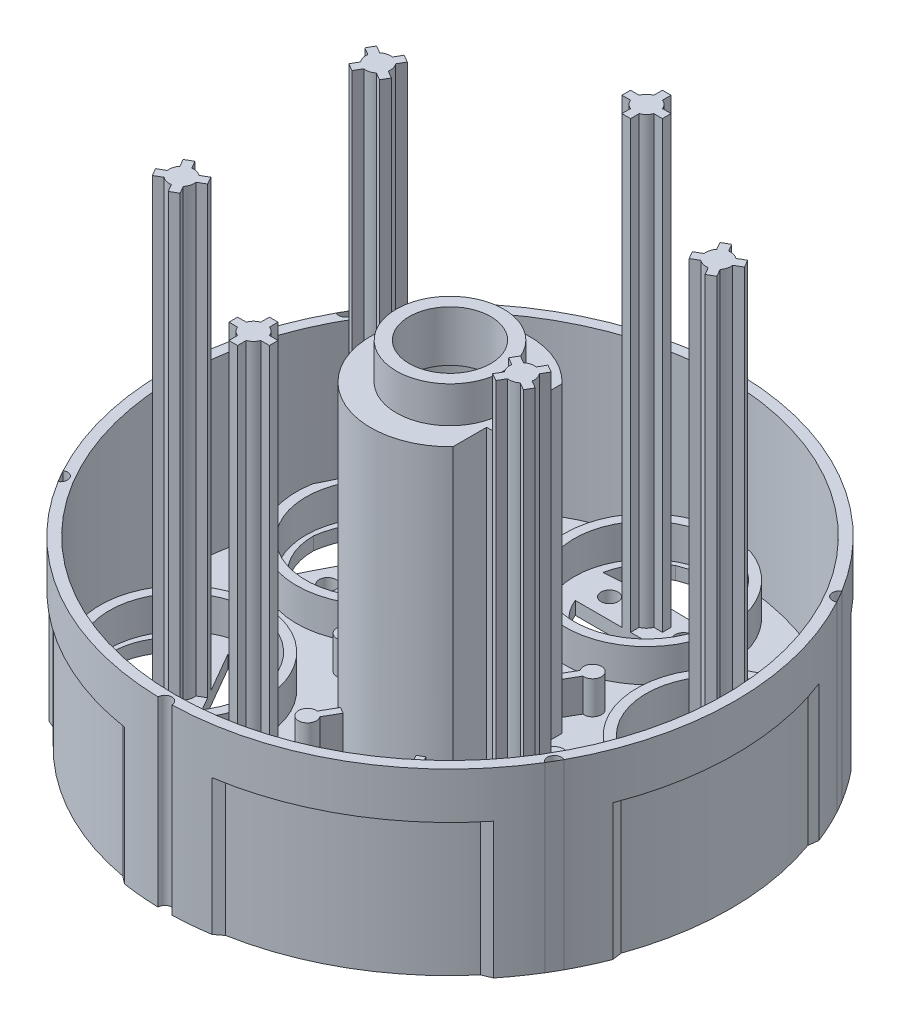
from build123d import *

# Parameters (mm, degrees)
SKETCH1_R           = 30.63
BOSS_EXTRUDE1_DEPTH = 19.56
SKETCH2_R           = 29.5
CUT_EXTRUDE1_DEPTH  = 18.17
SKETCH4_R           = 8.515
BOSS_EXTRUDE2_DEPTH = 36.43
SKETCH5_R           = 8.515
SKETCH5_R_2         = 5.765
CUT_EXTRUDE2_DEPTH  = 3.9
SKETCH6_R           = 4.38
CUT_EXTRUDE3_DEPTH  = 58.504314621
CUT_EXTRUDE4_DEPTH  = 32.53
CUT_EXTRUDE5_DEPTH  = 32.37
BOSS_EXTRUDE3_DEPTH = 3.54
SKETCH10_R          = 8.75
SKETCH10_R_2        = 7.75
BOSS_EXTRUDE7_DEPTH = 3.54
BOSS_EXTRUDE9_DEPTH = 47.8
SKETCH13_R          = 0.909625742
CUT_EXTRUDE8_DEPTH  = 65.507625906
CUT_EXTRUDE10_DEPTH = 14.59
CUT_EXTRUDE11_DEPTH = 66.544259093


with BuildPart() as part:
    # Sketch1 → Boss-Extrude1 (new body)
    with BuildSketch(Plane(origin=(0, 0, 0), x_dir=(1, 0, 0), z_dir=(0, 1, 0))):
        with Locations(Location((0, 0, 0), (0, 0, 270))):
            Circle(SKETCH1_R)
    extrude(amount=BOSS_EXTRUDE1_DEPTH)

    # Sketch2 → Cut-Extrude1 (cut)
    with BuildSketch(Plane(origin=(0, 19.56, 0), x_dir=(1, 0, 0), z_dir=(0, 1, 0))):
        with Locations(Location((0, 0, 0), (0, 0, 270))):
            Circle(SKETCH2_R)
    extrude(amount=-CUT_EXTRUDE1_DEPTH, mode=Mode.SUBTRACT)

    # Sketch4 → Boss-Extrude2 (add)
    with BuildSketch(Plane(origin=(0, 1.39, 0), x_dir=(1, 0, 0), z_dir=(0, 1, 0))):
        with Locations(Location((0, 0, 0), (0, 0, 90))):
            Circle(SKETCH4_R)
    extrude(amount=BOSS_EXTRUDE2_DEPTH)

    # Sketch5 → Cut-Extrude2 (cut)
    with BuildSketch(Plane(origin=(0, 37.82, 0), x_dir=(1, 0, 0), z_dir=(0, 1, 0))):
        with Locations(Location((0, 0, 0), (0, 0, 90))):
            Circle(SKETCH5_R)
        with Locations(Location((0, 0, 0), (0, 0, 270))):
            Circle(SKETCH5_R_2, mode=Mode.SUBTRACT)
    extrude(amount=-CUT_EXTRUDE2_DEPTH, mode=Mode.SUBTRACT)

    # Sketch6 → Cut-Extrude3 (cut, through all)
    with BuildSketch(Plane(origin=(0, 37.82, 0), x_dir=(1, 0, 0), z_dir=(0, 1, 0))):
        with Locations(Location((0, 0, 0), (0, 0, 270))):
            Circle(SKETCH6_R)
    extrude(amount=-CUT_EXTRUDE3_DEPTH, mode=Mode.SUBTRACT)

    # Sketch7 → Cut-Extrude4 (cut)
    with BuildSketch(Plane(origin=(0, 33.92, 0), x_dir=(1, 0, 0), z_dir=(0, 1, 0))):
        with BuildLine():
            Line((8.213720229, 2.245), (6.181644869, 2.245))
            Line((6.181644869, 2.245), (6.181644869, 5.855979142))
            ThreePointArc((6.181644869, 5.855979142), (7.420675621, 4.175978728), (8.213720229, 2.245))
        make_face()
        with BuildLine():
            Line((8.213720229, -2.245), (6.181644869, -2.245))
            Line((6.181644869, -2.245), (6.181644869, -5.855979142))
            ThreePointArc((6.181644869, -5.855979142), (7.420675621, -4.175978728), (8.213720229, -2.245))
        make_face()
    extrude(amount=-CUT_EXTRUDE4_DEPTH, mode=Mode.SUBTRACT)

    # Sketch8 → Cut-Extrude5 (cut)
    with BuildSketch(Plane.XZ):
        with BuildLine():
            Line((7.200999931, -1.035), (6.115, -1.035))
            Line((6.115, -1.035), (6.115, -3.941116593))
            ThreePointArc((6.115, -3.941116593), (-7.275, 0), (6.115, 3.941116593))
            Line((6.115, 3.941116593), (6.115, 1.035))
            Line((6.115, 1.035), (7.200999931, 1.035))
            ThreePointArc((7.200999931, 1.035), (7.275, 0), (7.200999931, -1.035))
        make_face()
    extrude(amount=-CUT_EXTRUDE5_DEPTH, mode=Mode.SUBTRACT)

    # Sketch9 → Boss-Extrude3 (add)
    with BuildSketch(Plane(origin=(0, 1.39, 0), x_dir=(1, 0, 0), z_dir=(0, 1, 0))):
        with BuildLine():
            Line((8.506232996, 0.386296797), (10.339031796, 0.386296797))
            ThreePointArc((10.339031796, 0.386296797), (12.171005542, 0), (10.339031796, -0.386296797))
            Line((10.339031796, -0.386296797), (8.506232996, -0.386296797))
            ThreePointArc((8.506232996, -0.386296797), (8.515, 0), (8.506232996, 0.386296797))
        make_face()
        with BuildLine():
            Line((4.587659337, -7.173465467), (5.504058737, -8.760715787))
            ThreePointArc((5.504058737, -8.760715787), (6.085502771, -10.540399989), (4.834973059, -9.147012584))
            Line((4.834973059, -9.147012584), (3.918573659, -7.559762263))
            ThreePointArc((3.918573659, -7.559762263), (4.2575, -7.374206313), (4.587659337, -7.173465467))
        make_face()
        with BuildLine():
            Line((-3.918573659, -7.559762263), (-4.834973059, -9.147012584))
            ThreePointArc((-4.834973059, -9.147012584), (-6.085502771, -10.540399989), (-5.504058737, -8.760715787))
            Line((-5.504058737, -8.760715787), (-4.587659337, -7.173465467))
            ThreePointArc((-4.587659337, -7.173465467), (-4.2575, -7.374206313), (-3.918573659, -7.559762263))
        make_face()
        with BuildLine():
            Line((-8.506232996, -0.386296797), (-10.339031796, -0.386296797))
            ThreePointArc((-10.339031796, -0.386296797), (-12.171005542, 0), (-10.339031796, 0.386296797))
            Line((-10.339031796, 0.386296797), (-8.506232996, 0.386296797))
            ThreePointArc((-8.506232996, 0.386296797), (-8.515, 0), (-8.506232996, -0.386296797))
        make_face()
        with BuildLine():
            Line((-4.587659337, 7.173465467), (-5.504058737, 8.760715787))
            ThreePointArc((-5.504058737, 8.760715787), (-6.085502771, 10.540399989), (-4.834973059, 9.147012584))
            Line((-4.834973059, 9.147012584), (-3.918573659, 7.559762263))
            ThreePointArc((-3.918573659, 7.559762263), (-4.2575, 7.374206313), (-4.587659337, 7.173465467))
        make_face()
        with BuildLine():
            Line((3.918573659, 7.559762263), (4.834973059, 9.147012584))
            ThreePointArc((4.834973059, 9.147012584), (6.085502771, 10.540399989), (5.504058737, 8.760715787))
            Line((5.504058737, 8.760715787), (4.587659337, 7.173465467))
            ThreePointArc((4.587659337, 7.173465467), (4.2575, 7.374206313), (3.918573659, 7.559762263))
        make_face()
    extrude(amount=BOSS_EXTRUDE3_DEPTH)

    # Sketch10 → Boss-Extrude7 (add)
    with BuildSketch(Plane(origin=(0, 1.39, 0), x_dir=(1, 0, 0), z_dir=(0, 1, 0))):
        with Locations((0, 21.110003347)):
            Circle(SKETCH10_R)
        with Locations(Location((0, 21.110003347, 0), (0, 0, 90))):
            Circle(SKETCH10_R_2, mode=Mode.SUBTRACT)
        with Locations((18.281799173, 10.555001674)):
            Circle(SKETCH10_R)
        with Locations(Location((18.281799173, 10.555001674, 0), (0, 0, 90))):
            Circle(SKETCH10_R_2, mode=Mode.SUBTRACT)
        with Locations((18.281799173, -10.555001674)):
            Circle(SKETCH10_R)
        with Locations(Location((18.281799173, -10.555001674, 0), (0, 0, 90))):
            Circle(SKETCH10_R_2, mode=Mode.SUBTRACT)
        with Locations((0, -21.110003347)):
            Circle(SKETCH10_R)
        with Locations(Location((0, -21.110003347, 0), (0, 0, 90))):
            Circle(SKETCH10_R_2, mode=Mode.SUBTRACT)
        with Locations((-18.281799173, -10.555001674)):
            Circle(SKETCH10_R)
        with Locations(Location((-18.281799173, -10.555001674, 0), (0, 0, 90))):
            Circle(SKETCH10_R_2, mode=Mode.SUBTRACT)
        with Locations((-18.281799173, 10.555001674)):
            Circle(SKETCH10_R)
        with Locations(Location((-18.281799173, 10.555001674, 0), (0, 0, 90))):
            Circle(SKETCH10_R_2, mode=Mode.SUBTRACT)
    extrude(amount=BOSS_EXTRUDE7_DEPTH)

    # Sketch11 → Boss-Extrude9 (add)
    with BuildSketch(Plane(origin=(0, 1.39, 0), x_dir=(1, 0, 0), z_dir=(0, 1, 0))):
        with BuildLine():
            Line((-0.465, 19.863939545), (-0.465, 18.935802576))
            Line((-0.465, 18.935802576), (0.465, 18.935802576))
            Line((0.465, 18.935802576), (0.465, 19.863939545))
            ThreePointArc((0.465, 19.863939545), (0.940452019, 20.169551328), (1.246063803, 20.645003347))
            Line((1.246063803, 20.645003347), (2.174200772, 20.645003347))
            Line((2.174200772, 20.645003347), (2.174200772, 21.575003347))
            Line((2.174200772, 21.575003347), (1.246063803, 21.575003347))
            ThreePointArc((1.246063803, 21.575003347), (0.940452019, 22.050455366), (0.465, 22.35606715))
            Line((0.465, 22.35606715), (0.465, 23.284204119))
            Line((0.465, 23.284204119), (-0.465, 23.284204119))
            Line((-0.465, 23.284204119), (-0.465, 22.35606715))
            ThreePointArc((-0.465, 22.35606715), (-0.940452019, 22.050455366), (-1.246063803, 21.575003347))
            Line((-1.246063803, 21.575003347), (-2.174200772, 21.575003347))
            Line((-2.174200772, 21.575003347), (-2.174200772, 20.645003347))
            Line((-2.174200772, 20.645003347), (-1.246063803, 20.645003347))
            ThreePointArc((-1.246063803, 20.645003347), (-0.940452019, 20.169551328), (-0.465, 19.863939545))
        make_face()
        with BuildLine():
            Line((16.970176265, 10.334671585), (16.166386071, 9.870603101))
            Line((16.166386071, 9.870603101), (16.631386071, 9.065199475))
            Line((16.631386071, 9.065199475), (17.435176265, 9.52926796))
            ThreePointArc((17.435176265, 9.52926796), (17.937569843, 9.270320325), (18.502129261, 9.243378766))
            Line((18.502129261, 9.243378766), (18.966197746, 8.439588572))
            Line((18.966197746, 8.439588572), (19.771601371, 8.904588572))
            Line((19.771601371, 8.904588572), (19.307532887, 9.708378766))
            ThreePointArc((19.307532887, 9.708378766), (19.566480522, 10.210772344), (19.59342208, 10.775331762))
            Line((19.59342208, 10.775331762), (20.397212274, 11.239400247))
            Line((20.397212274, 11.239400247), (19.932212274, 12.044803872))
            Line((19.932212274, 12.044803872), (19.12842208, 11.580735388))
            ThreePointArc((19.12842208, 11.580735388), (18.626028503, 11.839683023), (18.061469084, 11.866624581))
            Line((18.061469084, 11.866624581), (17.5974006, 12.670414775))
            Line((17.5974006, 12.670414775), (16.791996974, 12.205414775))
            Line((16.791996974, 12.205414775), (17.256065459, 11.401624581))
            ThreePointArc((17.256065459, 11.401624581), (16.997117824, 10.899231004), (16.970176265, 10.334671585))
        make_face()
        with BuildLine():
            Line((17.435176265, -9.52926796), (16.631386071, -9.065199475))
            Line((16.631386071, -9.065199475), (16.166386071, -9.870603101))
            Line((16.166386071, -9.870603101), (16.970176265, -10.334671585))
            ThreePointArc((16.970176265, -10.334671585), (16.997117824, -10.899231004), (17.256065459, -11.401624581))
            Line((17.256065459, -11.401624581), (16.791996974, -12.205414775))
            Line((16.791996974, -12.205414775), (17.5974006, -12.670414775))
            Line((17.5974006, -12.670414775), (18.061469084, -11.866624581))
            ThreePointArc((18.061469084, -11.866624581), (18.626028503, -11.839683023), (19.12842208, -11.580735388))
            Line((19.12842208, -11.580735388), (19.932212274, -12.044803872))
            Line((19.932212274, -12.044803872), (20.397212274, -11.239400247))
            Line((20.397212274, -11.239400247), (19.59342208, -10.775331762))
            ThreePointArc((19.59342208, -10.775331762), (19.566480522, -10.210772344), (19.307532887, -9.708378766))
            Line((19.307532887, -9.708378766), (19.771601371, -8.904588572))
            Line((19.771601371, -8.904588572), (18.966197746, -8.439588572))
            Line((18.966197746, -8.439588572), (18.502129261, -9.243378766))
            ThreePointArc((18.502129261, -9.243378766), (17.937569843, -9.270320325), (17.435176265, -9.52926796))
        make_face()
        with BuildLine():
            Line((0.465, -19.863939545), (0.465, -18.935802576))
            Line((0.465, -18.935802576), (-0.465, -18.935802576))
            Line((-0.465, -18.935802576), (-0.465, -19.863939545))
            ThreePointArc((-0.465, -19.863939545), (-0.940452019, -20.169551328), (-1.246063803, -20.645003347))
            Line((-1.246063803, -20.645003347), (-2.174200772, -20.645003347))
            Line((-2.174200772, -20.645003347), (-2.174200772, -21.575003347))
            Line((-2.174200772, -21.575003347), (-1.246063803, -21.575003347))
            ThreePointArc((-1.246063803, -21.575003347), (-0.940452019, -22.050455366), (-0.465, -22.35606715))
            Line((-0.465, -22.35606715), (-0.465, -23.284204119))
            Line((-0.465, -23.284204119), (0.465, -23.284204119))
            Line((0.465, -23.284204119), (0.465, -22.35606715))
            ThreePointArc((0.465, -22.35606715), (0.940452019, -22.050455366), (1.246063803, -21.575003347))
            Line((1.246063803, -21.575003347), (2.174200772, -21.575003347))
            Line((2.174200772, -21.575003347), (2.174200772, -20.645003347))
            Line((2.174200772, -20.645003347), (1.246063803, -20.645003347))
            ThreePointArc((1.246063803, -20.645003347), (0.940452019, -20.169551328), (0.465, -19.863939545))
        make_face()
        with BuildLine():
            Line((-16.970176265, -10.334671585), (-16.166386071, -9.870603101))
            Line((-16.166386071, -9.870603101), (-16.631386071, -9.065199475))
            Line((-16.631386071, -9.065199475), (-17.435176265, -9.52926796))
            ThreePointArc((-17.435176265, -9.52926796), (-17.937569843, -9.270320325), (-18.502129261, -9.243378766))
            Line((-18.502129261, -9.243378766), (-18.966197746, -8.439588572))
            Line((-18.966197746, -8.439588572), (-19.771601371, -8.904588572))
            Line((-19.771601371, -8.904588572), (-19.307532887, -9.708378766))
            ThreePointArc((-19.307532887, -9.708378766), (-19.566480522, -10.210772344), (-19.59342208, -10.775331762))
            Line((-19.59342208, -10.775331762), (-20.397212274, -11.239400247))
            Line((-20.397212274, -11.239400247), (-19.932212274, -12.044803872))
            Line((-19.932212274, -12.044803872), (-19.12842208, -11.580735388))
            ThreePointArc((-19.12842208, -11.580735388), (-18.626028503, -11.839683023), (-18.061469084, -11.866624581))
            Line((-18.061469084, -11.866624581), (-17.5974006, -12.670414775))
            Line((-17.5974006, -12.670414775), (-16.791996974, -12.205414775))
            Line((-16.791996974, -12.205414775), (-17.256065459, -11.401624581))
            ThreePointArc((-17.256065459, -11.401624581), (-16.997117824, -10.899231004), (-16.970176265, -10.334671585))
        make_face()
        with BuildLine():
            Line((-17.435176265, 9.52926796), (-16.631386071, 9.065199475))
            Line((-16.631386071, 9.065199475), (-16.166386071, 9.870603101))
            Line((-16.166386071, 9.870603101), (-16.970176265, 10.334671585))
            ThreePointArc((-16.970176265, 10.334671585), (-16.997117824, 10.899231004), (-17.256065459, 11.401624581))
            Line((-17.256065459, 11.401624581), (-16.791996974, 12.205414775))
            Line((-16.791996974, 12.205414775), (-17.5974006, 12.670414775))
            Line((-17.5974006, 12.670414775), (-18.061469084, 11.866624581))
            ThreePointArc((-18.061469084, 11.866624581), (-18.626028503, 11.839683023), (-19.12842208, 11.580735388))
            Line((-19.12842208, 11.580735388), (-19.932212274, 12.044803872))
            Line((-19.932212274, 12.044803872), (-20.397212274, 11.239400247))
            Line((-20.397212274, 11.239400247), (-19.59342208, 10.775331762))
            ThreePointArc((-19.59342208, 10.775331762), (-19.566480522, 10.210772344), (-19.307532887, 9.708378766))
            Line((-19.307532887, 9.708378766), (-19.771601371, 8.904588572))
            Line((-19.771601371, 8.904588572), (-18.966197746, 8.439588572))
            Line((-18.966197746, 8.439588572), (-18.502129261, 9.243378766))
            ThreePointArc((-18.502129261, 9.243378766), (-17.937569843, 9.270320325), (-17.435176265, 9.52926796))
        make_face()
    extrude(amount=BOSS_EXTRUDE9_DEPTH)

    # Sketch13 → Cut-Extrude8 (cut, through all)
    with BuildSketch(Plane(origin=(0, 1.39, 0), x_dir=(1, 0, 0), z_dir=(0, 1, 0))):
        with Locations(Location((-3.969867119, 21.110003347, 0), (0, 0, 270))):
            Circle(SKETCH13_R)
        with Locations(Location((3.969867119, 21.110003347, 0), (0, 0, 90))):
            Circle(SKETCH13_R)
        with Locations(Location((16.296865613, 13.993007448, 0), (0, 0, 270))):
            Circle(SKETCH13_R)
        with Locations(Location((20.266732732, 7.116995899, 0), (0, 0, 90))):
            Circle(SKETCH13_R)
        with Locations(Location((20.266732732, -7.116995899, 0), (0, 0, 270))):
            Circle(SKETCH13_R)
        with Locations(Location((16.296865613, -13.993007448, 0), (0, 0, 90))):
            Circle(SKETCH13_R)
        with Locations(Location((3.969867119, -21.110003347, 0), (0, 0, 270))):
            Circle(SKETCH13_R)
        with Locations(Location((-3.969867119, -21.110003347, 0), (0, 0, 90))):
            Circle(SKETCH13_R)
        with Locations(Location((-16.296865613, -13.993007448, 0), (0, 0, 270))):
            Circle(SKETCH13_R)
        with Locations(Location((-20.266732732, -7.116995899, 0), (0, 0, 90))):
            Circle(SKETCH13_R)
        with Locations(Location((-20.266732732, 7.116995899, 0), (0, 0, 270))):
            Circle(SKETCH13_R)
        with Locations(Location((-16.296865613, 13.993007448, 0), (0, 0, 90))):
            Circle(SKETCH13_R)
        with BuildLine():
            Line((-5.48, 18.935802576), (5.48, 18.935802576))
            ThreePointArc((5.48, 18.935802576), (0, 15.214450023), (-5.48, 18.935802576))
        make_face()
        with BuildLine():
            Line((13.658886071, 14.213720501), (19.138886071, 4.722082075))
            ThreePointArc((19.138886071, 4.722082075), (13.176100225, 7.607225012), (13.658886071, 14.213720501))
        make_face()
        with BuildLine():
            Line((19.138886071, -4.722082075), (13.658886071, -14.213720501))
            ThreePointArc((13.658886071, -14.213720501), (13.176100225, -7.607225012), (19.138886071, -4.722082075))
        make_face()
        with BuildLine():
            Line((5.48, -18.935802576), (-5.48, -18.935802576))
            ThreePointArc((-5.48, -18.935802576), (0, -15.214450023), (5.48, -18.935802576))
        make_face()
        with BuildLine():
            Line((-13.658886071, -14.213720501), (-19.138886071, -4.722082075))
            ThreePointArc((-19.138886071, -4.722082075), (-13.176100225, -7.607225012), (-13.658886071, -14.213720501))
        make_face()
        with BuildLine():
            Line((-19.138886071, 4.722082075), (-13.658886071, 14.213720501))
            ThreePointArc((-13.658886071, 14.213720501), (-13.176100225, 7.607225012), (-19.138886071, 4.722082075))
        make_face()
        with BuildLine():
            ThreePointArc((-6.59, 23.02237811), (5.3181e-05, 23.284202431), (6.59, 23.01971456))
            ThreePointArc((6.59, 23.01971456), (5.488364869, 25.676260481), (3.327964884, 27.574551317))
            ThreePointArc((3.327964884, 27.574551317), (0, 28.220671786), (-3.327964884, 27.574551317))
            ThreePointArc((-3.327964884, 27.574551317), (-5.455420975, 25.654206873), (-6.59, 23.02237811))
        make_face()
        with BuildLine():
            ThreePointArc((23.230657597, 5.802749869), (24.980476285, 8.085066839), (25.54424438, 10.905173526))
            ThreePointArc((25.54424438, 10.905173526), (24.439818679, 14.110335893), (22.216279496, 16.669377791))
            ThreePointArc((22.216279496, 16.669377791), (19.489484378, 17.551636589), (16.642964299, 17.218296466))
            ThreePointArc((16.642964299, 17.218296466), (20.164737403, 11.642055159), (23.230657597, 5.802749869))
        make_face()
        with BuildLine():
            ThreePointArc((16.640657597, -17.216964691), (19.492111416, -17.591193642), (22.216279496, -16.669377791))
            ThreePointArc((22.216279496, -16.669377791), (24.439818679, -14.110335893), (25.54424438, -10.905173526))
            ThreePointArc((25.54424438, -10.905173526), (24.944905354, -8.102570284), (23.232964299, -5.804081644))
            ThreePointArc((23.232964299, -5.804081644), (20.164684222, -11.642147272), (16.640657597, -17.216964691))
        make_face()
        with BuildLine():
            ThreePointArc((-6.59, -23.01971456), (-5.488364869, -25.676260481), (-3.327964884, -27.574551317))
            ThreePointArc((-3.327964884, -27.574551317), (0, -28.220671786), (3.327964884, -27.574551317))
            ThreePointArc((3.327964884, -27.574551317), (5.455420975, -25.654206873), (6.59, -23.02237811))
            ThreePointArc((6.59, -23.02237811), (-5.3181e-05, -23.284202431), (-6.59, -23.01971456))
        make_face()
        with BuildLine():
            ThreePointArc((-23.230657597, -5.802749869), (-24.980476285, -8.085066839), (-25.54424438, -10.905173526))
            ThreePointArc((-25.54424438, -10.905173526), (-24.439818679, -14.110335893), (-22.216279496, -16.669377791))
            ThreePointArc((-22.216279496, -16.669377791), (-19.489484378, -17.551636589), (-16.642964299, -17.218296466))
            ThreePointArc((-16.642964299, -17.218296466), (-20.164737403, -11.642055159), (-23.230657597, -5.802749869))
        make_face()
        with BuildLine():
            ThreePointArc((-16.640657597, 17.216964691), (-19.492111416, 17.591193642), (-22.216279496, 16.669377791))
            ThreePointArc((-22.216279496, 16.669377791), (-24.439818679, 14.110335893), (-25.54424438, 10.905173526))
            ThreePointArc((-25.54424438, 10.905173526), (-24.944905354, 8.102570284), (-23.232964299, 5.804081644))
            ThreePointArc((-23.232964299, 5.804081644), (-20.164684222, 11.642147272), (-16.640657597, 17.216964691))
        make_face()
    extrude(amount=-CUT_EXTRUDE8_DEPTH, mode=Mode.SUBTRACT)

    # Sketch14 → Cut-Extrude10 (cut)
    with BuildSketch(Plane.XZ):
        with BuildLine():
            Line((5.527046845, 29.627158367), (4.691881752, 30.2685174))
            ThreePointArc((4.691881752, 30.2685174), (15.315, 26.526358118), (23.867364127, 19.197547489))
            Line((23.867364127, 19.197547489), (22.894348365, 19.600142159))
            ThreePointArc((22.894348365, 19.600142159), (15.081074357, 26.121187019), (5.527046845, 29.627158367))
        make_face()
        with BuildLine():
            Line((-5.527046845, 29.627158367), (-4.691881752, 30.2685174))
            ThreePointArc((-4.691881752, 30.2685174), (-15.315, 26.526358118), (-23.867364127, 19.197547489))
            Line((-23.867364127, 19.197547489), (-22.894348365, 19.600142159))
            ThreePointArc((-22.894348365, 19.600142159), (-15.081074357, 26.121187019), (-5.527046845, 29.627158367))
        make_face()
        with BuildLine():
            Line((28.42139521, 10.027016207), (28.55924588, 11.070969911))
            ThreePointArc((28.55924588, 11.070969911), (30.63, 0), (28.55924588, -11.070969911))
            Line((28.55924588, -11.070969911), (28.42139521, -10.027016207))
            ThreePointArc((28.42139521, -10.027016207), (30.162148714, 0), (28.42139521, 10.027016207))
        make_face()
        with BuildLine():
            Line((22.894348365, -19.600142159), (23.867364127, -19.197547489))
            ThreePointArc((23.867364127, -19.197547489), (15.315, -26.526358118), (4.691881752, -30.2685174))
            Line((4.691881752, -30.2685174), (5.527046845, -29.627158367))
            ThreePointArc((5.527046845, -29.627158367), (15.081074357, -26.121187019), (22.894348365, -19.600142159))
        make_face()
        with BuildLine():
            Line((-5.527046845, -29.627158367), (-4.691881752, -30.2685174))
            ThreePointArc((-4.691881752, -30.2685174), (-15.315, -26.526358118), (-23.867364127, -19.197547489))
            Line((-23.867364127, -19.197547489), (-22.894348365, -19.600142159))
            ThreePointArc((-22.894348365, -19.600142159), (-15.081074357, -26.121187019), (-5.527046845, -29.627158367))
        make_face()
        with BuildLine():
            Line((-28.42139521, -10.027016207), (-28.55924588, -11.070969911))
            ThreePointArc((-28.55924588, -11.070969911), (-30.63, 0), (-28.55924588, 11.070969911))
            Line((-28.55924588, 11.070969911), (-28.42139521, 10.027016207))
            ThreePointArc((-28.42139521, 10.027016207), (-30.162148714, 0), (-28.42139521, -10.027016207))
        make_face()
    extrude(amount=-CUT_EXTRUDE10_DEPTH, mode=Mode.SUBTRACT)

    # Sketch16 → Cut-Extrude11 (cut, through all)
    with BuildSketch(Plane.XZ):
        with BuildLine():
            Line((26.143845526, 15.959205528), (26.893000175, 14.661631614))
            ThreePointArc((26.893000175, 14.661631614), (25.877522635, 14.940394659), (26.143845526, 15.959205528))
        make_face()
        with BuildLine():
            Line((26.893000175, -14.661631614), (26.143845526, -15.959205528))
            ThreePointArc((26.143845526, -15.959205528), (25.877522635, -14.940394659), (26.893000175, -14.661631614))
        make_face()
        with BuildLine():
            Line((0.749154649, -30.620837143), (-0.749154649, -30.620837143))
            ThreePointArc((-0.749154649, -30.620837143), (0, -29.880789318), (0.749154649, -30.620837143))
        make_face()
        with BuildLine():
            Line((-26.143845526, -15.959205528), (-26.893000175, -14.661631614))
            ThreePointArc((-26.893000175, -14.661631614), (-25.877522635, -14.940394659), (-26.143845526, -15.959205528))
        make_face()
        with BuildLine():
            Line((-26.893000175, 14.661631614), (-26.143845526, 15.959205528))
            ThreePointArc((-26.143845526, 15.959205528), (-25.877522635, 14.940394659), (-26.893000175, 14.661631614))
        make_face()
        with BuildLine():
            Line((-0.749154649, 30.620837143), (-0.749154649, 30.86494064))
            Line((-0.749154649, 30.86494064), (0.749154649, 30.86494064))
            Line((0.749154649, 30.86494064), (0.749154649, 30.620837143))
            ThreePointArc((0.749154649, 30.620837143), (0, 29.880789318), (-0.749154649, 30.620837143))
        make_face()
    extrude(amount=-CUT_EXTRUDE11_DEPTH, mode=Mode.SUBTRACT)


solid = part.part
